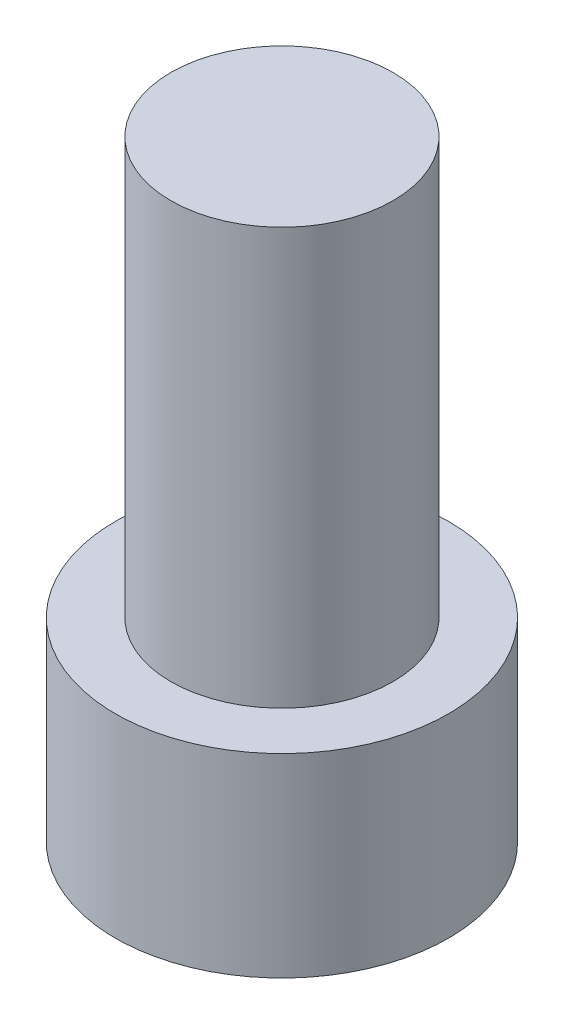
from build123d import *

# Parameters (mm, degrees)
SKETCH1_R           = 4
BOSS_EXTRUDE1_DEPTH = 15
SKETCH2_R           = 6
SKETCH2_R_2         = 4
BOSS_EXTRUDE2_DEPTH = 2
SKETCH3_R           = 6
BOSS_EXTRUDE3_DEPTH = 5


with BuildPart() as part:
    # Sketch1 → Boss-Extrude1 (new body)
    with BuildSketch(Plane(origin=(0, 0, 0), x_dir=(1, 0, 0), z_dir=(0, 1, 0))):
        with Locations(Location((0, 0, 0), (0, 0, 270))):
            Circle(SKETCH1_R)
    extrude(amount=BOSS_EXTRUDE1_DEPTH)


with BuildPart() as body_2:
    # Sketch2 → Boss-Extrude2 (new body)
    with BuildSketch(Plane.XZ):
        with Locations(Location((0, 0, 0), (0, 0, 270))):
            Circle(SKETCH2_R)
        with Locations(Location((0, 0, 0), (0, 0, 90))):
            Circle(SKETCH2_R_2, mode=Mode.SUBTRACT)
        with Locations(Location((0, 0, 0), (0, 0, 90))):
            Circle(SKETCH2_R_2)
    extrude(amount=BOSS_EXTRUDE2_DEPTH)

    # Sketch3 → Boss-Extrude3 (add)
    with BuildSketch(Plane.XZ.offset(2)):
        with Locations(Location((0, 0, 0), (0, 0, 270))):
            Circle(SKETCH3_R)
        Polygon((4.618802154, 0), (2.309401077, 4), (-2.309401077, 4), (-4.618802154, 0), (-2.309401077, -4), (2.309401077, -4), align=None, mode=Mode.SUBTRACT)
    extrude(amount=BOSS_EXTRUDE3_DEPTH)


solid = Compound([part.part, body_2.part])
